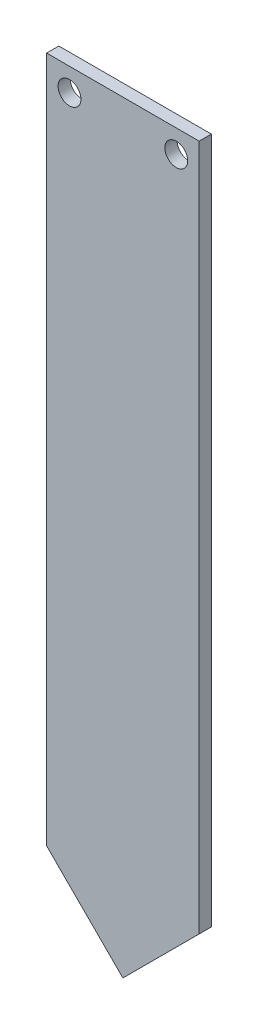
from build123d import *

# Parameters (mm, degrees)
IZIM1_R                     = 1.5
Y_KSEKLIK_EKSTR_ZYON1_DEPTH = 1.6


with BuildPart() as part:
    # Çizim1 → Yükseklik-Ekstrüzyon1 (new body)
    with BuildSketch(Plane.XY):
        Polygon((0, -55), (-10, -45), (-10, 45), (10, 45), (10, -45), align=None)
        with Locations((-7, 42)):
            Circle(IZIM1_R, mode=Mode.SUBTRACT)
        with Locations((7, 42)):
            Circle(IZIM1_R, mode=Mode.SUBTRACT)
    extrude(amount=Y_KSEKLIK_EKSTR_ZYON1_DEPTH)


solid = part.part
